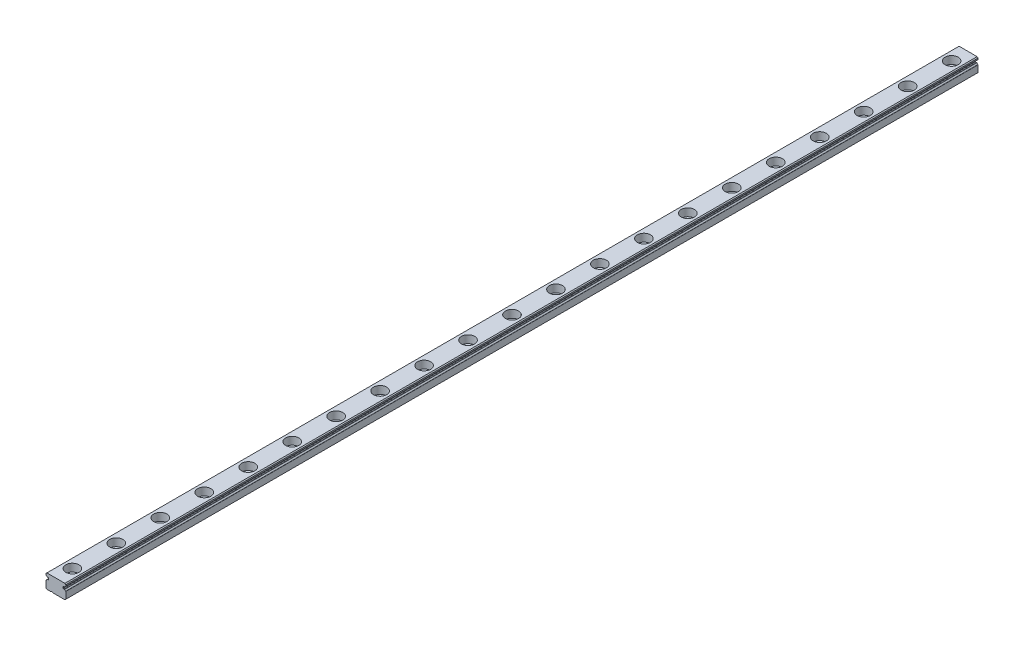
from build123d import *

# Parameters (mm, degrees)
BOSS_EXTRUDE1_DEPTH = 207.5
SKETCH3_R           = 1.75
CUT_EXTRUDE2_DEPTH  = 208.650547796
SKETCH3_3_R         = 3
SKETCH3_3_R_2       = 1.75
CUT_EXTRUDE3_DEPTH  = 3.5


with BuildPart() as part:
    # Sketch1 → Boss-Extrude1 (new, symmetric)
    with BuildSketch(Plane.XY):
        with BuildLine():
            Line((-1.4, -6.5), (4.1, -6.5))
            Line((4.1, -6.5), (4.5, -6.1))
            Line((4.5, -6.1), (4.5, -3.058303524))
            ThreePointArc((4.5, -3.058303524), (4.475108648, -2.975551932), (4.408695652, -2.920264326))
            ThreePointArc((4.408695652, -2.920264326), (4.141262777, -2.752376093), (3.939510483, -2.509471145))
            ThreePointArc((3.939510483, -2.509471145), (3.890337026, -2.458942579), (3.823510417, -2.436462162))
            Line((3.823510417, -2.436462162), (3.482568852, -2.40663364))
            ThreePointArc((3.482568852, -2.40663364), (3.352544533, -2.342512742), (3.3, -2.207394701))
            Line((3.3, -2.207394701), (3.3, -1.792605299))
            ThreePointArc((3.3, -1.792605299), (3.352544533, -1.657487258), (3.482568852, -1.59336636))
            Line((3.482568852, -1.59336636), (3.823514163, -1.56353751))
            ThreePointArc((3.823514163, -1.56353751), (3.890340367, -1.541057348), (3.939513741, -1.490529352))
            ThreePointArc((3.939513741, -1.490529352), (4.141265182, -1.247627801), (4.408695652, -1.079741674))
            ThreePointArc((4.408695652, -1.079741674), (4.475108648, -1.024454068), (4.5, -0.941702476))
            Line((4.5, -0.941702476), (4.5, -0.4))
            Line((4.5, -0.4), (4.1, 0))
            Line((4.1, 0), (-4.1, 0))
            Line((-4.1, 0), (-4.5, -0.4))
            Line((-4.5, -0.4), (-4.5, -0.941702476))
            ThreePointArc((-4.5, -0.941702476), (-4.475108648, -1.024454068), (-4.408695652, -1.079741674))
            ThreePointArc((-4.408695652, -1.079741674), (-4.141265182, -1.247627801), (-3.939513741, -1.490529352))
            ThreePointArc((-3.939513741, -1.490529352), (-3.890340367, -1.541057348), (-3.823514163, -1.56353751))
            Line((-3.823514163, -1.56353751), (-3.482568852, -1.59336636))
            ThreePointArc((-3.482568852, -1.59336636), (-3.352544533, -1.657487258), (-3.3, -1.792605299))
            Line((-3.3, -1.792605299), (-3.3, -2.207394701))
            ThreePointArc((-3.3, -2.207394701), (-3.352544533, -2.342512742), (-3.482568852, -2.40663364))
            Line((-3.482568852, -2.40663364), (-3.823510417, -2.436462162))
            ThreePointArc((-3.823510417, -2.436462162), (-3.890337026, -2.458942579), (-3.939510483, -2.509471145))
            ThreePointArc((-3.939510483, -2.509471145), (-4.141262777, -2.752376093), (-4.408695652, -2.920264326))
            ThreePointArc((-4.408695652, -2.920264326), (-4.475108648, -2.975551932), (-4.5, -3.058303524))
            Line((-4.5, -3.058303524), (-4.5, -6.1))
            Line((-4.5, -6.1), (-4.1, -6.5))
            Line((-4.1, -6.5), (-2.2, -6.5))
            ThreePointArc((-2.2, -6.5), (-1.8, -6.3), (-1.4, -6.5))
        make_face()
    extrude(amount=BOSS_EXTRUDE1_DEPTH, both=True)

    # Sketch3 → Cut-Extrude2 (cut, through all)
    with BuildSketch(Plane(origin=(0, 0, 0), x_dir=(1, 0, 0), z_dir=(0, 1, 0))):
        with Locations(Location((0, -200, 0), (0, 0, 180))):
            Circle(SKETCH3_R)
    cut_extrude2 = extrude(amount=-CUT_EXTRUDE2_DEPTH, mode=Mode.SUBTRACT)

    # Sketch3_3 → Cut-Extrude3 (cut)
    with BuildSketch(Plane(origin=(0, 0, 0), x_dir=(1, 0, 0), z_dir=(0, 1, 0))):
        with Locations(Location((0, -200, 0), (0, 0, 180))):
            Circle(SKETCH3_3_R)
        with Locations(Location((0, -200, 0), (0, 0, 180))):
            Circle(SKETCH3_3_R_2, mode=Mode.SUBTRACT)
    cut_extrude3 = extrude(amount=-CUT_EXTRUDE3_DEPTH, mode=Mode.SUBTRACT)

    # Sketch-Pattern1: Cut-Extrude2, Cut-Extrude3 at 29 more places
    with Locations((0, 0, -20), (0, 0, -40), (0, 0, -60), (0, 0, -80), (0, 0, -100), (0, 0, -120), (0, 0, -140), (0, 0, -160), (0, 0, -180), (0, 0, -200), (0, 0, -220), (0, 0, -240), (0, 0, -260), (0, 0, -280), (0, 0, -300), (0, 0, -320), (0, 0, -340), (0, 0, -360), (0, 0, -380), (0, 0, -400), (0, 0, -420), (0, 0, -440), (0, 0, -460), (0, 0, -480), (0, 0, -500), (0, 0, -520), (0, 0, -540), (0, 0, -560), (0, 0, -580)):
        add(cut_extrude2, mode=Mode.SUBTRACT)
        add(cut_extrude3, mode=Mode.SUBTRACT)


solid = part.part
